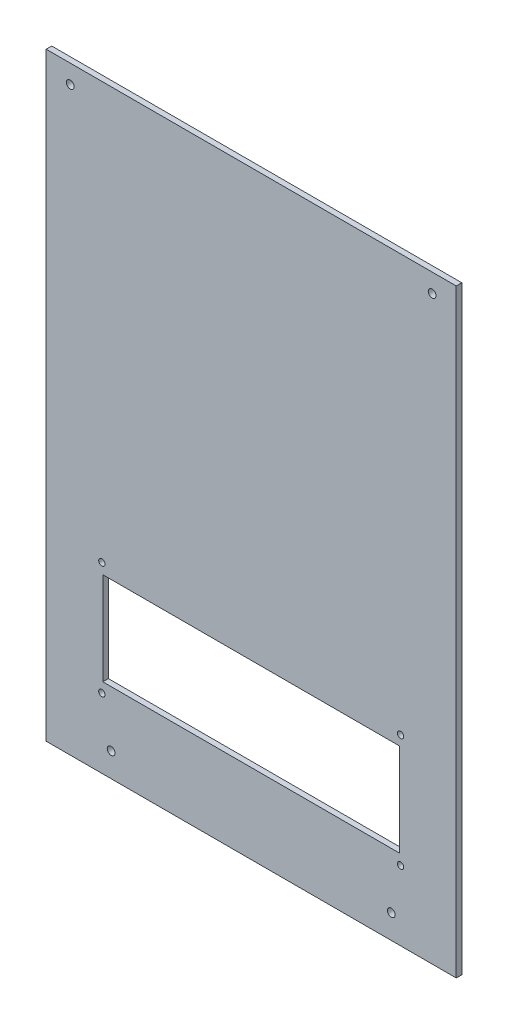
from build123d import *

# Parameters (mm, degrees)
SKETCH1_W                 = 221
SKETCH1_H                 = 323
BOSS_EXTRUDE1_DEPTH       = 3
SKETCH2_W                 = 160
SKETCH2_H                 = 50
CUT_EXTRUDE1_DEPTH        = 4
CUT_EXTRUDE2_REACH        = 5
SKETCH5_R                 = 1.7
F_4_0MM_DOWEL_HOLE1_D     = 4.2
F_4_0MM_DOWEL_HOLE1_DEPTH = 3


with BuildPart() as part:
    # Sketch1 → Boss-Extrude1 (new body)
    with BuildSketch(Plane(origin=(0, 0, -125.5), x_dir=(-1, 0, 0), z_dir=(0, 0, -1))):
        with Locations((0, 148.5)):
            Rectangle(SKETCH1_W, SKETCH1_H)
    extrude(amount=-BOSS_EXTRUDE1_DEPTH)

    # Sketch2 → Cut-Extrude1 (cut, through all)
    with BuildSketch(Plane.XY.offset(-122.5)):
        with Locations((0, 55)):
            Rectangle(SKETCH2_W, SKETCH2_H)
    extrude(amount=-CUT_EXTRUDE1_DEPTH, mode=Mode.SUBTRACT)

    # Sketch5 → Cut-Extrude2 (cut, up to next)
    with BuildSketch(Plane(origin=(0, 0, -125.5), x_dir=(-1, 0, 0), z_dir=(0, 0, -1)), mode=Mode.PRIVATE) as cut_extrude2_sk1:
        with Locations((80.5, 85.5)):
            Circle(SKETCH5_R)
    cut_extrude2_tool1 = extrude(cut_extrude2_sk1.sketch, amount=-CUT_EXTRUDE2_REACH, mode=Mode.PRIVATE) & part.part
    add(cut_extrude2_tool1.solids().sort_by_distance((-80.5, 85.5, -125.5))[0], mode=Mode.SUBTRACT)
    # Sketch5 → Cut-Extrude2 (cut, up to next)
    with BuildSketch(Plane(origin=(0, 0, -125.5), x_dir=(-1, 0, 0), z_dir=(0, 0, -1)), mode=Mode.PRIVATE) as cut_extrude2_sk2:
        with Locations((80.5, 24.5)):
            Circle(SKETCH5_R)
    cut_extrude2_tool2 = extrude(cut_extrude2_sk2.sketch, amount=-CUT_EXTRUDE2_REACH, mode=Mode.PRIVATE) & part.part
    add(cut_extrude2_tool2.solids().sort_by_distance((-80.5, 24.5, -125.5))[0], mode=Mode.SUBTRACT)
    # Sketch5 → Cut-Extrude2 (cut, up to next)
    with BuildSketch(Plane(origin=(0, 0, -125.5), x_dir=(-1, 0, 0), z_dir=(0, 0, -1)), mode=Mode.PRIVATE) as cut_extrude2_sk3:
        with Locations((-80.5, 24.5)):
            Circle(SKETCH5_R)
    cut_extrude2_tool3 = extrude(cut_extrude2_sk3.sketch, amount=-CUT_EXTRUDE2_REACH, mode=Mode.PRIVATE) & part.part
    add(cut_extrude2_tool3.solids().sort_by_distance((80.5, 24.5, -125.5))[0], mode=Mode.SUBTRACT)
    # Sketch5 → Cut-Extrude2 (cut, up to next)
    with BuildSketch(Plane(origin=(0, 0, -125.5), x_dir=(-1, 0, 0), z_dir=(0, 0, -1)), mode=Mode.PRIVATE) as cut_extrude2_sk4:
        with Locations((-80.5, 85.5)):
            Circle(SKETCH5_R)
    cut_extrude2_tool4 = extrude(cut_extrude2_sk4.sketch, amount=-CUT_EXTRUDE2_REACH, mode=Mode.PRIVATE) & part.part
    add(cut_extrude2_tool4.solids().sort_by_distance((80.5, 85.5, -125.5))[0], mode=Mode.SUBTRACT)

    # Ø4.0mm Dowel Hole1
    with Locations(Plane.XY.offset(-122.5)):
        with Locations((-97.5, 300), (97.5, 300), (75.5, 0), (-75.5, 0)):
            Hole(F_4_0MM_DOWEL_HOLE1_D / 2, depth=F_4_0MM_DOWEL_HOLE1_DEPTH)


solid = part.part
